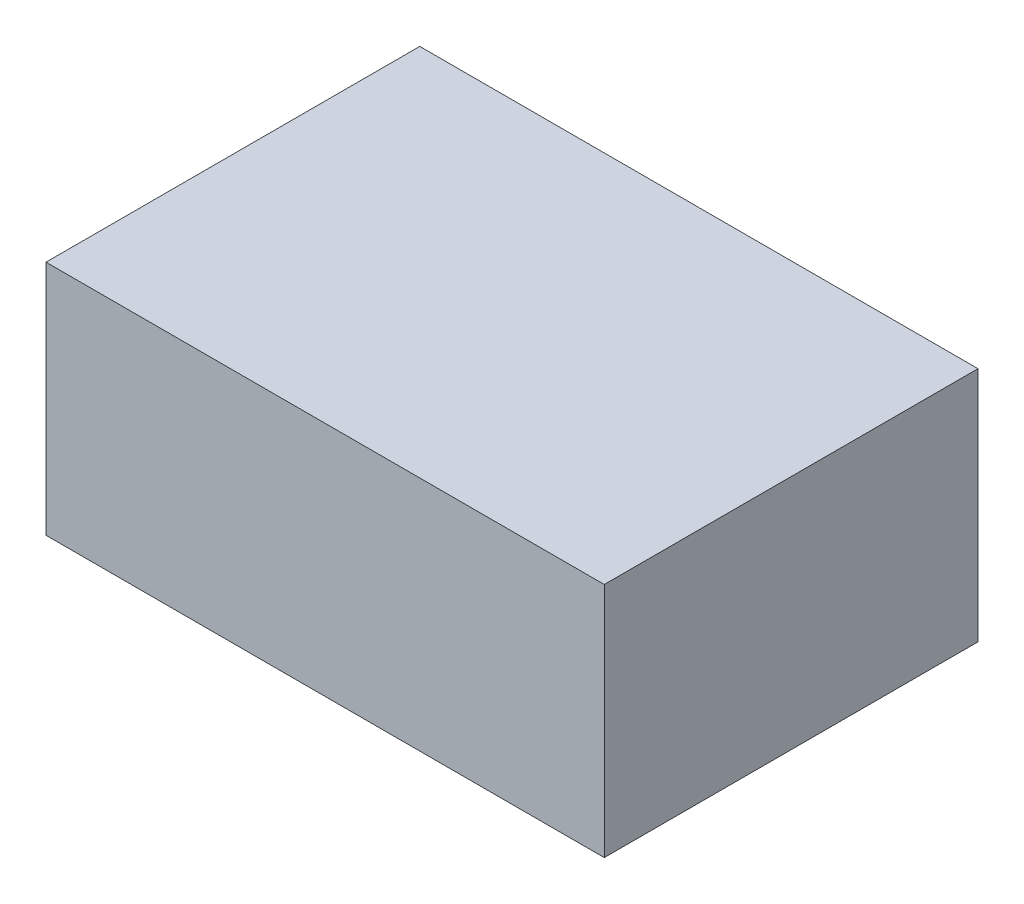
from build123d import *

# Parameters (mm, degrees)
SKETCH1_W           = 2.9972
SKETCH1_H           = 2.0066
BOSS_EXTRUDE1_DEPTH = 1.27


with BuildPart() as part:
    # Sketch1 → Boss-Extrude1 (new body)
    with BuildSketch(Plane(origin=(0, 0, 0), x_dir=(1, 0, 0), z_dir=(0, 1, 0))):
        Rectangle(SKETCH1_W, SKETCH1_H)
    extrude(amount=BOSS_EXTRUDE1_DEPTH)


solid = part.part
